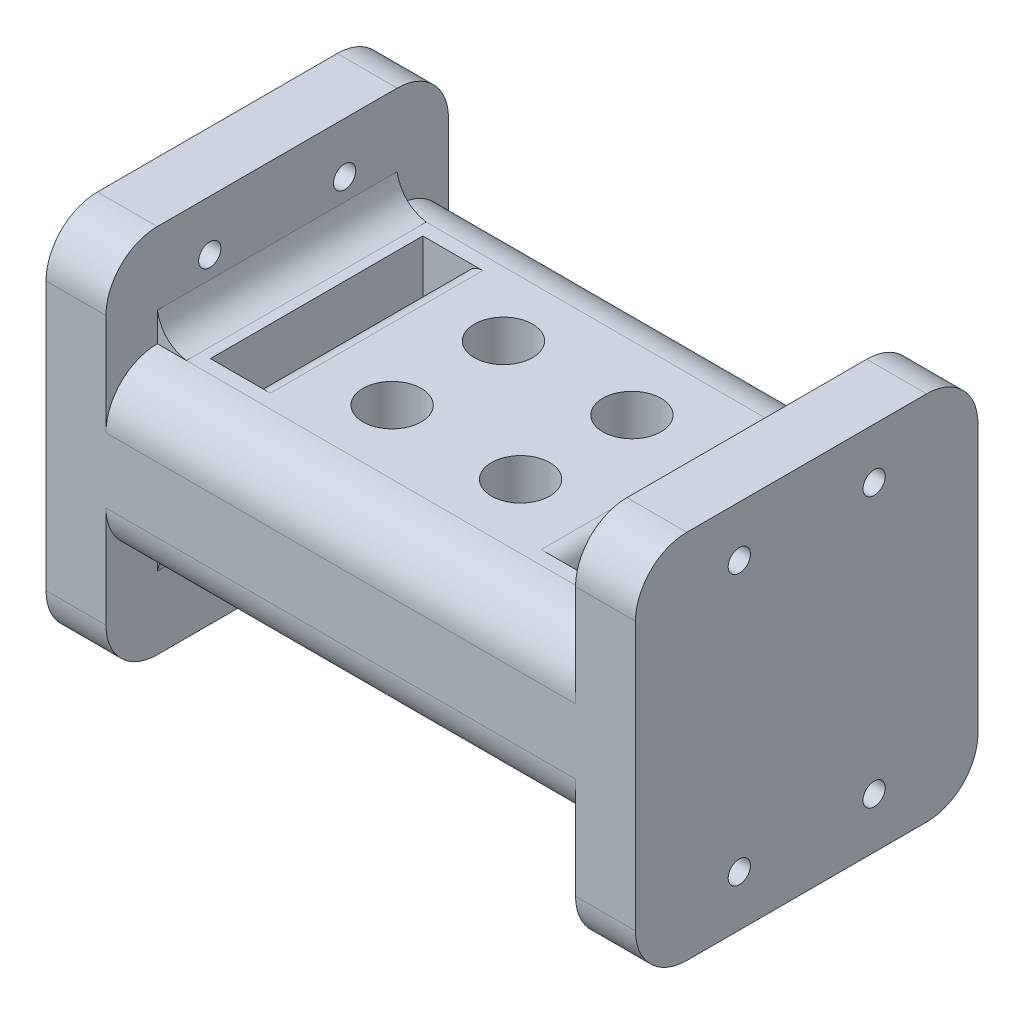
from build123d import *

# Parameters (mm, degrees)
SKETCH1_W            = 50.8
SKETCH1_H            = 55
SKETCH1_R            = 1.651
BOSS_EXTRUDE1_DEPTH  = 8.89
FILLET1_R            = 7.62
SKETCH2_W            = 50.8
SKETCH2_H            = 24.892
BOSS_EXTRUDE2_DEPTH  = 34.81959
FILLET2_R            = 7.62
SKETCH7_R            = 4.318
CUT_EXTRUDE4_DEPTH   = 40.946
BOSS_EXTRUDE4_START  = -7.62
BOSS_EXTRUDE4_DEPTH  = 35.56
MIRROR9_START        = -7.62
MIRROR9_COPY_1_DEPTH = 35.56
SKETCH10_W           = 6.35
SKETCH10_H           = 31.496
CUT_EXTRUDE5_DEPTH   = 40.946
FILLET4_R            = 2.54


with BuildPart() as part:
    # Sketch1 → Boss-Extrude1 (new body)
    with BuildSketch(Plane(origin=(0, 0, 0), x_dir=(0, 0, -1), z_dir=(1, 0, 0))):
        Rectangle(SKETCH1_W, SKETCH1_H)
        with Locations((-10, 20)):
            Circle(SKETCH1_R, mode=Mode.SUBTRACT)
        with Locations((10, 20)):
            Circle(SKETCH1_R, mode=Mode.SUBTRACT)
        with Locations((-10, -20)):
            Circle(SKETCH1_R, mode=Mode.SUBTRACT)
        with Locations((10, -20)):
            Circle(SKETCH1_R, mode=Mode.SUBTRACT)
    extrude(amount=BOSS_EXTRUDE1_DEPTH)

    # Fillet1
    fillet1_edges = [part.edges().sort_by_distance(p)[0] for p in [
        (4.445, 27.5, 25.4),
        (4.445, 27.5, -25.4),
        (4.445, -27.5, -25.4),
        (4.445, -27.5, 25.4),
    ]]
    fillet(fillet1_edges, radius=FILLET1_R)

    # Sketch2 → Boss-Extrude2 (add)
    with BuildSketch(Plane(origin=(8.89, 0, 0), x_dir=(0, 0, -1), z_dir=(1, 0, 0))):
        Rectangle(SKETCH2_W, SKETCH2_H)
    extrude(amount=BOSS_EXTRUDE2_DEPTH)

    # Fillet2
    fillet2_edges = [part.edges().sort_by_distance(p)[0] for p in [
        (26.299795, 12.446, 25.4),
        (26.299795, -12.446, 25.4),
        (26.299795, -12.446, -25.4),
        (26.299795, 12.446, -25.4),
    ]]
    fillet(fillet2_edges, radius=FILLET2_R)

    # Mirror6: part across plane


with BuildPart() as part_1:
    add(part.part)
    add(part.part.mirror(Plane(origin=(43.70959, 0, 0), x_dir=(0, 0, 1), z_dir=(1, 0, 0))))

    # Sketch7 → Cut-Extrude4 (cut, through all)
    with BuildSketch(Plane(origin=(0, 12.446, 0), x_dir=(1, 0, 0), z_dir=(0, 1, 0))):
        with Locations((34.18459, 8.255)):
            Circle(SKETCH7_R)
        with Locations((34.18459, -8.255)):
            Circle(SKETCH7_R)
        with Locations((53.23459, 8.255)):
            Circle(SKETCH7_R)
        with Locations((53.23459, -8.255)):
            Circle(SKETCH7_R)
    extrude(amount=-CUT_EXTRUDE4_DEPTH, mode=Mode.SUBTRACT)

    # Sketch9 → Boss-Extrude4 (add)
    with BuildSketch(Plane.XY.offset(25.4).offset(BOSS_EXTRUDE4_START)):
        with BuildLine():
            Line((10.326840979, 13.882840979), (8.89, 12.446))
            Line((8.89, 12.446), (13.208, 12.446))
            add(Edge.make_bspline(
                [(10.326840979, 13.882840979), (11.406340979, 12.803340979), (13.208, 12.446)],
                knots=[0.5, 0.5, 0.5, 1, 1, 1], degree=2))
        make_face()
        with BuildLine():
            add(Edge.make_bspline(
                [(8.89, 16.764), (9.247340979, 14.962340979), (10.326840979, 13.882840979)],
                knots=[0, 0, 0, 0.5, 0.5, 0.5], degree=2))
            Line((8.89, 16.764), (8.89, 12.446))
            Line((8.89, 12.446), (10.326840979, 13.882840979))
        make_face()
    boss_extrude4 = extrude(amount=-BOSS_EXTRUDE4_DEPTH)

    # Mirror8: Boss-Extrude4 across plane
    add(boss_extrude4.mirror(Plane.ZX))

    # Mirror9: Boss-Extrude4 across plane
    add(boss_extrude4.mirror(Plane(origin=(43.70959, 0, 0), x_dir=(0, 0, 1), z_dir=(1, 0, 0))))

    # Mirror9 copy 1 sketch → Mirror9 copy 1 (add)
    with BuildSketch(Plane(origin=(87.41918, 0, 25.4), x_dir=(-1, 0, 0), z_dir=(0, 0, 1)).offset(MIRROR9_START)):
        with BuildLine():
            Line((10.326840979, 13.882840979), (8.89, 12.446))
            Line((8.89, 12.446), (13.208, 12.446))
            add(Edge.make_bspline(
                [(10.326840979, 13.882840979), (11.406340979, 12.803340979), (13.208, 12.446)],
                knots=[0.5, 0.5, 0.5, 1, 1, 1], degree=2))
        make_face()
        with BuildLine():
            add(Edge.make_bspline(
                [(8.89, 16.764), (9.247340979, 14.962340979), (10.326840979, 13.882840979)],
                knots=[0, 0, 0, 0.5, 0.5, 0.5], degree=2))
            Line((8.89, 16.764), (8.89, 12.446))
            Line((8.89, 12.446), (10.326840979, 13.882840979))
        make_face()
    extrude(amount=-MIRROR9_COPY_1_DEPTH)

    # Sketch10 → Cut-Extrude5 (cut, through all)
    with BuildSketch(Plane(origin=(0, 12.446, 0), x_dir=(1, 0, 0), z_dir=(0, 1, 0))):
        with Locations((17.907, 0)):
            Rectangle(SKETCH10_W, SKETCH10_H)
    cut_extrude5 = extrude(amount=-CUT_EXTRUDE5_DEPTH, mode=Mode.SUBTRACT)

    # Mirror10: Cut-Extrude5 across plane
    add(cut_extrude5.mirror(Plane(origin=(43.70959, 0, 0), x_dir=(0, 0, 1), z_dir=(1, 0, 0))), mode=Mode.SUBTRACT)

    # Fillet4
    fillet4_edges = [part_1.edges().sort_by_distance(p)[0] for p in [
        (21.082, -12.446, 0),
        (21.082, 12.446, 0),
        (66.33718, 12.446, 0),
        (66.33718, -12.446, 0),
    ]]
    fillet(fillet4_edges, radius=FILLET4_R)


solid = part_1.part
